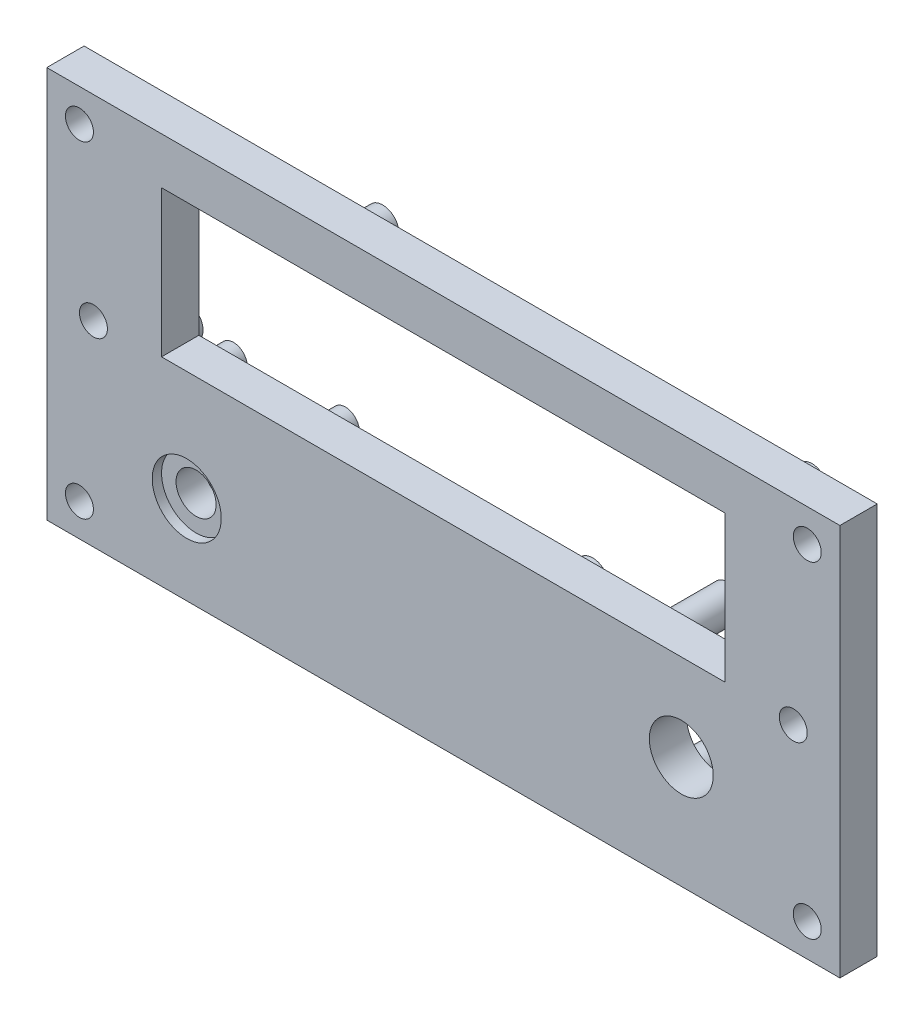
from build123d import *

# Parameters (mm, degrees)
SKETCH1_W                           = 85
SKETCH1_H                           = 42
BOTTOM_PLATE_DEPTH                  = 4
SKETCH2_R                           = 1.5
BOTTOM_PLATE_SCREW_HOLES_DEPTH      = 1
BOTTOM_PLATE_SCREW_HOLES_DEPTH_BACK = 5
SKETCH15_R                          = 1.5
TOP_PLATE_SCREWS_HOLES_DEPTH        = 1
TOP_PLATE_SCREWS_HOLES_DEPTH_BACK   = 2.5
SKETCH5_W                           = 60.4
SKETCH5_H                           = 15.7
LED_DEPTH                           = 1
LED_DEPTH_BACK                      = 5
SKETCH16_R                          = 1.75
LED_BOARD_SUPPORT_DEPTH             = 2
SKETCH17_R                          = 1
LED_BOARD_SCREWS_HOLES_DEPTH        = 5
SKETCH6_R                           = 2.15
TESTBUTTON_CUT_DEPTH                = 1
TESTBUTTON_CUT_DEPTH_BACK           = 7
SKETCH10_R                          = 3.7
TESTBUTTON_BIG_CUT_DEPTH            = 1
SKETCH13_R                          = 1.5
TEST_BOARD_SUPPORT_DEPTH            = 7
SKETCH14_R                          = 1
TEST_BOARD_SCREWS_HOLE_DEPTH        = 5
SKETCH9_R                           = 3.425
BRT_ADD_DEPTH                       = 6
SKETCH11_R                          = 1.75
POT_BOARD_SUPPORT_DEPTH             = 8
SKETCH12_R                          = 1
POT_BOARD_SCREWS_HOLE_DEPTH         = 5


with BuildPart() as part:
    # Sketch1 → Bottom Plate (new body)
    with BuildSketch(Plane.XY):
        Rectangle(SKETCH1_W, SKETCH1_H)
    extrude(amount=BOTTOM_PLATE_DEPTH)

    # Sketch2 → Bottom Plate Screw Holes (cut, two sides)
    with BuildSketch(Plane.XY.offset(4)) as bottom_plate_screw_holes_sk:
        with Locations((-39, 17.5)):
            Circle(SKETCH2_R)
        with Locations((-39, -17.5)):
            Circle(SKETCH2_R)
        with Locations((39, -17.5)):
            Circle(SKETCH2_R)
        with Locations((39, 17.5)):
            Circle(SKETCH2_R)
    extrude(amount=BOTTOM_PLATE_SCREW_HOLES_DEPTH, mode=Mode.SUBTRACT)
    extrude(bottom_plate_screw_holes_sk.sketch, amount=-BOTTOM_PLATE_SCREW_HOLES_DEPTH_BACK, mode=Mode.SUBTRACT)

    # Sketch15 → Top Plate Screws Holes (cut, two sides)
    with BuildSketch(Plane.XY.offset(4)) as top_plate_screws_holes_sk:
        with Locations((-37.5, 0)):
            Circle(SKETCH15_R)
        with Locations((37.5, 0)):
            Circle(SKETCH15_R)
    extrude(amount=TOP_PLATE_SCREWS_HOLES_DEPTH, mode=Mode.SUBTRACT)
    extrude(top_plate_screws_holes_sk.sketch, amount=-TOP_PLATE_SCREWS_HOLES_DEPTH_BACK, mode=Mode.SUBTRACT)

    # Sketch5 → LED (cut, two sides)
    with BuildSketch(Plane.XY.offset(4)) as led_sk:
        with Locations((0, 8.15)):
            Rectangle(SKETCH5_W, SKETCH5_H)
    extrude(amount=LED_DEPTH, mode=Mode.SUBTRACT)
    extrude(led_sk.sketch, amount=-LED_DEPTH_BACK, mode=Mode.SUBTRACT)

    # Sketch16 → LED Board Support (add)
    with BuildSketch(Plane(origin=(0, 0, 0), x_dir=(-1, 0, 0), z_dir=(0, 0, -1))):
        with Locations((-33.5, 17.5)):
            Circle(SKETCH16_R)
        with Locations((-10, -3)):
            Circle(SKETCH16_R)
        with Locations((33.5, -1)):
            Circle(SKETCH16_R)
        with Locations((12.5, 18.5)):
            Circle(SKETCH16_R)
        with Locations((13.75, -16.5)):
            Circle(SKETCH16_R)
    extrude(amount=LED_BOARD_SUPPORT_DEPTH)

    # Sketch17 → Led Board Screws Holes (cut)
    with BuildSketch(Plane(origin=(0, 0, -2), x_dir=(-1, 0, 0), z_dir=(0, 0, -1))):
        with Locations((-33.5, 17.5)):
            Circle(SKETCH17_R)
        with Locations((-10, -3)):
            Circle(SKETCH17_R)
        with Locations((12.5, 18.5)):
            Circle(SKETCH17_R)
        with Locations((33.5, -1)):
            Circle(SKETCH17_R)
        with Locations((13.75, -16.5)):
            Circle(SKETCH17_R)
    extrude(amount=-LED_BOARD_SCREWS_HOLES_DEPTH, mode=Mode.SUBTRACT)

    # Sketch6 → TestButton Cut (cut, two sides)
    with BuildSketch(Plane.XY.offset(4)) as testbutton_cut_sk:
        with Locations((-27.5, -11.5)):
            Circle(SKETCH6_R)
    extrude(amount=TESTBUTTON_CUT_DEPTH, mode=Mode.SUBTRACT)
    extrude(testbutton_cut_sk.sketch, amount=-TESTBUTTON_CUT_DEPTH_BACK, mode=Mode.SUBTRACT)

    # Sketch10 → TestButton Big Cut (cut)
    with BuildSketch(Plane.XY.offset(4)):
        with Locations((-27.5, -11.5)):
            Circle(SKETCH10_R)
    extrude(amount=-TESTBUTTON_BIG_CUT_DEPTH, mode=Mode.SUBTRACT)

    # Sketch13 → Test Board Support (add)
    with BuildSketch(Plane(origin=(0, 0, 0), x_dir=(-1, 0, 0), z_dir=(0, 0, -1))):
        with Locations((21.5, -7)):
            Circle(SKETCH13_R)
        with Locations((33.5, -7)):
            Circle(SKETCH13_R)
        with Locations((33.5, -16)):
            Circle(SKETCH13_R)
        with Locations((21.5, -16)):
            Circle(SKETCH13_R)
    extrude(amount=TEST_BOARD_SUPPORT_DEPTH)

    # Sketch14 → Test Board Screws Hole (cut)
    with BuildSketch(Plane(origin=(0, 0, -7), x_dir=(-1, 0, 0), z_dir=(0, 0, -1))):
        with Locations((21.5, -16)):
            Circle(SKETCH14_R)
        with Locations((21.5, -7)):
            Circle(SKETCH14_R)
        with Locations((33.5, -7)):
            Circle(SKETCH14_R)
        with Locations((33.5, -16)):
            Circle(SKETCH14_R)
    extrude(amount=-TEST_BOARD_SCREWS_HOLE_DEPTH, mode=Mode.SUBTRACT)

    # Sketch9 → Brt Add (cut)
    with BuildSketch(Plane(origin=(0, 0, 0), x_dir=(-1, 0, 0), z_dir=(0, 0, -1))):
        with Locations((-25.5, -9)):
            Circle(SKETCH9_R)
    extrude(amount=-BRT_ADD_DEPTH, mode=Mode.SUBTRACT)

    # Sketch11 → Pot Board Support (add)
    with BuildSketch(Plane(origin=(0, 0, 0), x_dir=(-1, 0, 0), z_dir=(0, 0, -1))):
        with Locations((-32.5, -4)):
            Circle(SKETCH11_R)
        with Locations((-18.5, -4)):
            Circle(SKETCH11_R)
        with Locations((-18.5, -18)):
            Circle(SKETCH11_R)
        with Locations((-32.5, -18)):
            Circle(SKETCH11_R)
    extrude(amount=POT_BOARD_SUPPORT_DEPTH)

    # Sketch12 → Pot Board Screws Hole (cut)
    with BuildSketch(Plane(origin=(0, 0, -8), x_dir=(-1, 0, 0), z_dir=(0, 0, -1))):
        with Locations((-32.5, -4)):
            Circle(SKETCH12_R)
        with Locations((-18.5, -4)):
            Circle(SKETCH12_R)
        with Locations((-18.5, -18)):
            Circle(SKETCH12_R)
        with Locations((-32.5, -18)):
            Circle(SKETCH12_R)
    extrude(amount=-POT_BOARD_SCREWS_HOLE_DEPTH, mode=Mode.SUBTRACT)


solid = part.part
